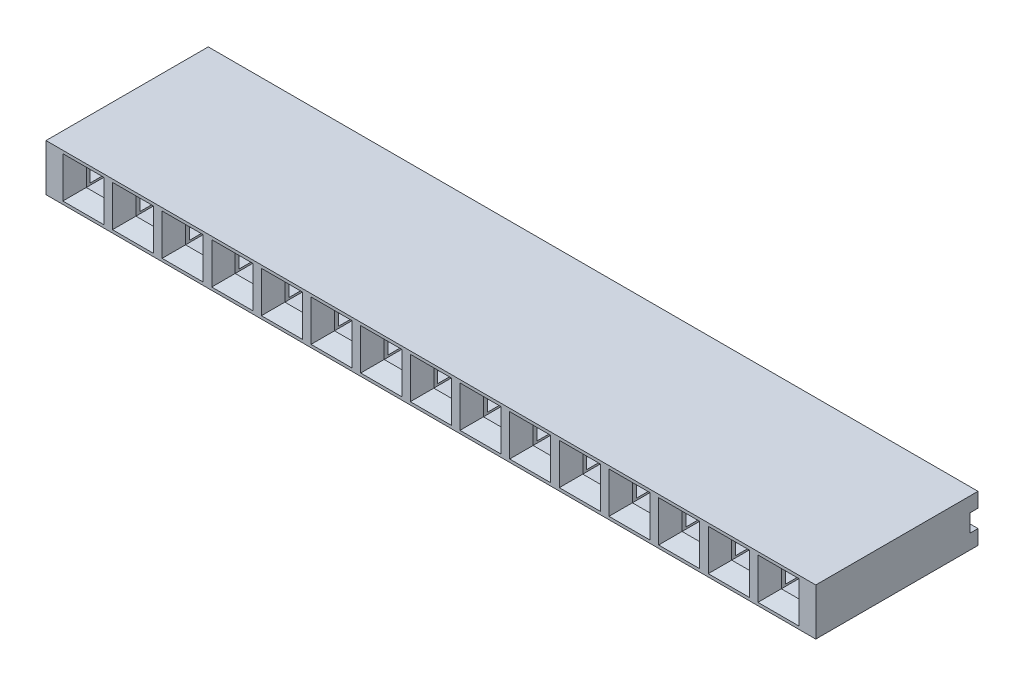
from build123d import *

# Parameters (mm, degrees)
SKETCH_229_W              = 2.54
SKETCH_229_H              = 2.4
EXTRUDE_706_DEPTH         = 6.7
EXTRUDE_706_DEPTH_BACK    = 0.4
SKETCH_760_W              = 2.54
SKETCH_760_H              = 0.75
EXTRUDE_1139_DEPTH        = 0.4
SKETCH_1193_W             = 2.54
SKETCH_1193_H             = 2.4
SKETCH_1193_W_2           = 0.9
SKETCH_1193_H_2           = 0.9
EXTRUDE_1478_DEPTH        = 0.8
CHAMFER_1539_SIZE         = 0.6
PATTERN_LINEAR_1665_COUNT = 15
PATTERN_LINEAR_1665_PITCH = 2.54
EXTRUDE_1_DEPTH           = 0.64
EXTRUDE_START             = -38.74
EXTRUDE_2_DEPTH           = 0.64


with BuildPart() as part:
    # Sketch 229 → Extrude 706 (new body, two sides)
    with BuildSketch(Plane.XY) as extrude_706_sk:
        Rectangle(SKETCH_229_W, SKETCH_229_H)
        Polygon((-1, 0.35), (-0.45, 0.35), (-0.45, 0.45), (0.45, 0.45), (0.45, 0.35), (1, 0.35), (1, -0.35), (0.45, -0.35), (0.45, -0.45), (-0.45, -0.45), (-0.45, -0.35), (-1, -0.35), align=None, mode=Mode.SUBTRACT)
    extrude(amount=EXTRUDE_706_DEPTH)
    extrude(extrude_706_sk.sketch, amount=-EXTRUDE_706_DEPTH_BACK)

    # Sketch 760 → Extrude 1139 (add)
    with BuildSketch(Plane(origin=(0, 0, -0.4), x_dir=(-1, 0, 0), z_dir=(0, 0, -1))):
        with Locations((0, -0.825)):
            Rectangle(SKETCH_760_W, SKETCH_760_H)
        with Locations((0, 0.825)):
            Rectangle(SKETCH_760_W, SKETCH_760_H)
    extrude(amount=EXTRUDE_1139_DEPTH)

    # Sketch 1193 → Extrude 1478 (add)
    with BuildSketch(Plane.XY.offset(6.7)):
        Rectangle(SKETCH_1193_W, SKETCH_1193_H)
        Rectangle(SKETCH_1193_W_2, SKETCH_1193_H_2, mode=Mode.SUBTRACT)
    extrude(amount=EXTRUDE_1478_DEPTH)

    # Chamfer 1539
    chamfer_1539_edges = [part.edges().sort_by_distance(p)[0] for p in [
        (0.45, 0, 7.5),
        (0, 0.45, 7.5),
        (-0.45, 0, 7.5),
        (0, -0.45, 7.5),
    ]]
    chamfer(chamfer_1539_edges, length=CHAMFER_1539_SIZE)


with BuildPart() as pattern_linear_1665_1:
    # Pattern Linear 1665: pattern copy
    add(part.part.moved(Location(Vector(-1, 0, 0) * (1 * PATTERN_LINEAR_1665_PITCH))))


with BuildPart() as pattern_linear_1665_2:
    # Pattern Linear 1665: pattern copy
    add(part.part.moved(Location(Vector(-1, 0, 0) * (2 * PATTERN_LINEAR_1665_PITCH))))


with BuildPart() as pattern_linear_1665_3:
    # Pattern Linear 1665: pattern copy
    add(part.part.moved(Location(Vector(-1, 0, 0) * (3 * PATTERN_LINEAR_1665_PITCH))))


with BuildPart() as pattern_linear_1665_4:
    # Pattern Linear 1665: pattern copy
    add(part.part.moved(Location(Vector(-1, 0, 0) * (4 * PATTERN_LINEAR_1665_PITCH))))


with BuildPart() as pattern_linear_1665_5:
    # Pattern Linear 1665: pattern copy
    add(part.part.moved(Location(Vector(-1, 0, 0) * (5 * PATTERN_LINEAR_1665_PITCH))))


with BuildPart() as pattern_linear_1665_6:
    # Pattern Linear 1665: pattern copy
    add(part.part.moved(Location(Vector(-1, 0, 0) * (6 * PATTERN_LINEAR_1665_PITCH))))


with BuildPart() as pattern_linear_1665_7:
    # Pattern Linear 1665: pattern copy
    add(part.part.moved(Location(Vector(-1, 0, 0) * (7 * PATTERN_LINEAR_1665_PITCH))))


with BuildPart() as pattern_linear_1665_8:
    # Pattern Linear 1665: pattern copy
    add(part.part.moved(Location(Vector(-1, 0, 0) * (8 * PATTERN_LINEAR_1665_PITCH))))


with BuildPart() as pattern_linear_1665_9:
    # Pattern Linear 1665: pattern copy
    add(part.part.moved(Location(Vector(-1, 0, 0) * (9 * PATTERN_LINEAR_1665_PITCH))))


with BuildPart() as pattern_linear_1665_10:
    # Pattern Linear 1665: pattern copy
    add(part.part.moved(Location(Vector(-1, 0, 0) * (10 * PATTERN_LINEAR_1665_PITCH))))


with BuildPart() as pattern_linear_1665_11:
    # Pattern Linear 1665: pattern copy
    add(part.part.moved(Location(Vector(-1, 0, 0) * (11 * PATTERN_LINEAR_1665_PITCH))))


with BuildPart() as pattern_linear_1665_12:
    # Pattern Linear 1665: pattern copy
    add(part.part.moved(Location(Vector(-1, 0, 0) * (12 * PATTERN_LINEAR_1665_PITCH))))


with BuildPart() as pattern_linear_1665_13:
    # Pattern Linear 1665: pattern copy
    add(part.part.moved(Location(Vector(-1, 0, 0) * (13 * PATTERN_LINEAR_1665_PITCH))))


with BuildPart() as pattern_linear_1665_14:
    # Pattern Linear 1665: pattern copy
    add(part.part.moved(Location(Vector(-1, 0, 0) * (14 * PATTERN_LINEAR_1665_PITCH))))


with BuildPart() as part_1:
    add(part.part)

    # Combine 1781: union Pattern Linear 1665_14, Pattern Linear 1665_13, Pattern Linear 1665_12, Pattern Linear 1665_11, Pattern Linear 1665_10, Pattern Linear 1665_9, Pattern Linear 1665_8, Pattern Linear 1665_7, Pattern Linear 1665_6, Pattern Linear 1665_5, Pattern Linear 1665_4, Pattern Linear 1665_3, Pattern Linear 1665_2, Pattern Linear 1665_1
    add(pattern_linear_1665_14.part)
    add(pattern_linear_1665_13.part)
    add(pattern_linear_1665_12.part)
    add(pattern_linear_1665_11.part)
    add(pattern_linear_1665_10.part)
    add(pattern_linear_1665_9.part)
    add(pattern_linear_1665_8.part)
    add(pattern_linear_1665_7.part)
    add(pattern_linear_1665_6.part)
    add(pattern_linear_1665_5.part)
    add(pattern_linear_1665_4.part)
    add(pattern_linear_1665_3.part)
    add(pattern_linear_1665_2.part)
    add(pattern_linear_1665_1.part)

    # Sketch 2589 → Бобышка-БоковаяНакладка1 (add)
    with BuildSketch(Plane(origin=(1.27, 0, 0), x_dir=(0, 0, -1), z_dir=(1, 0, 0))):
        Polygon((0.8, 1.2), (0.8, 0.45), (0.4, 0.45), (0.4, -0.45), (0.8, -0.45), (0.8, -1.2), (-7.5, -1.2), (-7.5, 1.2), align=None)
    extrude(amount=EXTRUDE_1_DEPTH)

    # Эскиз-БоковаяНакладка<2> → Бобышка-БоковаяНакладка2 (add)
    with BuildSketch(Plane(origin=(1.27, 0, 0), x_dir=(0, 0, -1), z_dir=(1, 0, 0)).offset(EXTRUDE_START)):
        Polygon((0.8, 1.2), (0.8, 0.45), (0.4, 0.45), (0.4, -0.45), (0.8, -0.45), (0.8, -1.2), (-7.5, -1.2), (-7.5, 1.2), align=None)
    extrude(amount=EXTRUDE_2_DEPTH)


solid = part_1.part
